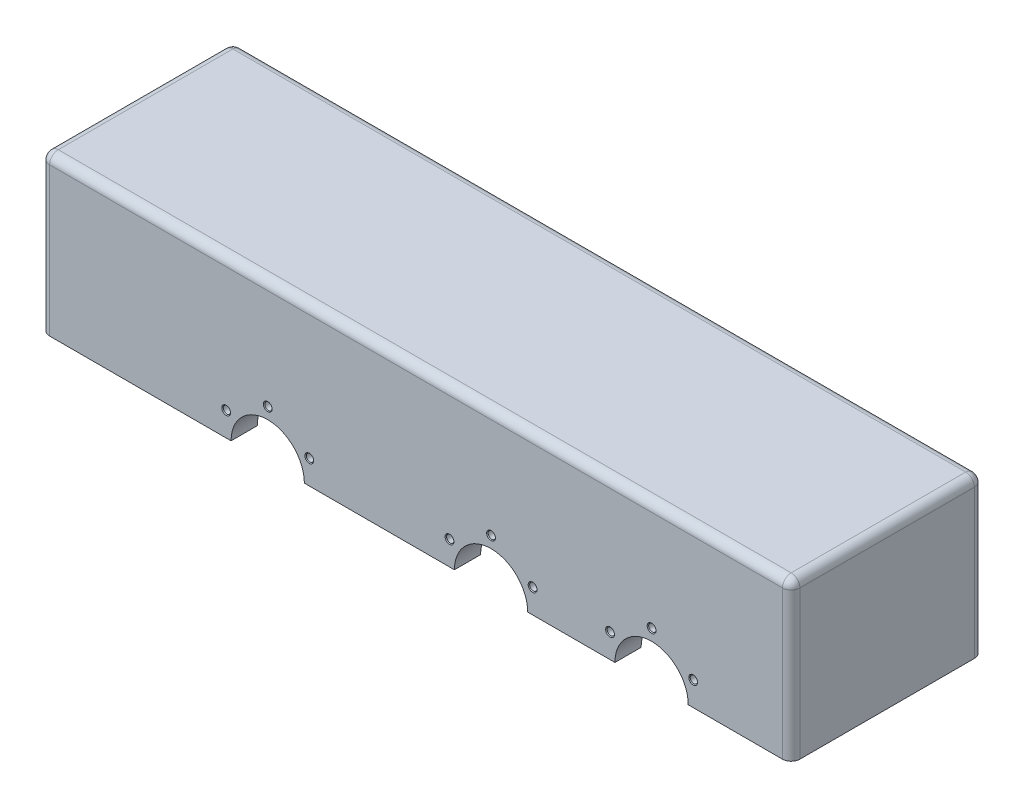
from build123d import *

# Parameters (mm, degrees)
SKETCH1_W           = 430
SKETCH1_H           = 110
SKETCH1_W_2         = 400
SKETCH1_H_2         = 80
BOSS_EXTRUDE1_DEPTH = 80
SKETCH2_W           = 430
SKETCH2_H           = 110
BOSS_EXTRUDE2_DEPTH = 10
SKETCH3_R           = 21
CUT_EXTRUDE1_DEPTH  = 196
FILLET1_R           = 5
CIRPATTERN1_COUNT   = 6
CIRPATTERN2_COUNT   = 6
CIRPATTERN3_COUNT   = 6


with BuildPart() as part:
    # Sketch1 → Boss-Extrude1 (new body)
    with BuildSketch(Plane(origin=(0, 0, 0), x_dir=(1, 0, 0), z_dir=(0, 1, 0))):
        Rectangle(SKETCH1_W, SKETCH1_H)
        Rectangle(SKETCH1_W_2, SKETCH1_H_2, mode=Mode.SUBTRACT)
    extrude(amount=BOSS_EXTRUDE1_DEPTH)

    # Sketch2 → Boss-Extrude2 (add)
    with BuildSketch(Plane(origin=(0, 80, 0), x_dir=(1, 0, 0), z_dir=(0, 1, 0))):
        Rectangle(SKETCH2_W, SKETCH2_H)
    extrude(amount=BOSS_EXTRUDE2_DEPTH)

    # Sketch3 → Cut-Extrude1 (cut)
    with BuildSketch(Plane.XY.offset(55)):
        with Locations((135, 0)):
            Circle(SKETCH3_R)
        with Locations((43, 0)):
            Circle(SKETCH3_R)
        with Locations((-85, 0)):
            Circle(SKETCH3_R)
    extrude(amount=-CUT_EXTRUDE1_DEPTH, mode=Mode.SUBTRACT)

    # Fillet1
    fillet1_edges = [part.edges().sort_by_distance(p)[0] for p in [
        (200, 40, 40),
        (200, 40, -40),
        (-200, 40, -40),
        (-200, 40, 40),
        (200, 80, 0),
        (0, 80, -40),
        (-200, 80, 0),
        (0, 80, 40),
        (215, 90, 0),
        (0, 90, -55),
        (-215, 90, 0),
        (0, 90, 55),
        (215, 45, 55),
        (-215, 45, 55),
        (-215, 45, -55),
        (215, 45, -55),
    ]]
    fillet(fillet1_edges, radius=FILLET1_R)

    # Sketch6 → M5 Tapped Hole1 (revolve, cut)
    with BuildSketch(Plane(origin=(158.815698604, 13.75, -55), x_dir=(0, 1, 0), z_dir=(1, 0, 0))):
        Polygon((0, 0), (0, 13.6618073), (2.1, 12.4), (2.1, 0.425), (2.525, 0), align=None)
    m5_tapped_hole1 = revolve(axis=Axis((158.815698604, 13.75, -61.35), (0, 0, 1)), mode=Mode.SUBTRACT)

    # Sketch7 → M5 Tapped Hole2 (revolve, cut)
    with BuildSketch(Plane(origin=(66.815698604, 13.75, -55), x_dir=(0, 1, 0), z_dir=(1, 0, 0))):
        Polygon((0, 0), (0, 13.6618073), (2.1, 12.4), (2.1, 0.425), (2.525, 0), align=None)
    m5_tapped_hole2 = revolve(axis=Axis((66.815698604, 13.75, -61.35), (0, 0, 1)), mode=Mode.SUBTRACT)

    # Sketch10 → M5 Tapped Hole3 (revolve, cut)
    with BuildSketch(Plane(origin=(-61.184301396, 13.75, -55), x_dir=(0, 1, 0), z_dir=(1, 0, 0))):
        Polygon((0, 0), (0, 13.6618073), (2.1, 12.4), (2.1, 0.425), (2.525, 0), align=None)
    m5_tapped_hole3 = revolve(axis=Axis((-61.184301396, 13.75, -61.35), (0, 0, 1)), mode=Mode.SUBTRACT)

    # CirPattern1: M5 Tapped Hole1 ×6 about axis, 3 skipped
    cirpattern1_axis = Axis((135, 0, 0), (0, 0, 1))
    add([m5_tapped_hole1.rotate(cirpattern1_axis, i * 360 / CIRPATTERN1_COUNT) for i in range(1, CIRPATTERN1_COUNT) if i not in (3, 4, 5)], mode=Mode.SUBTRACT)

    # CirPattern2: M5 Tapped Hole2 ×6 about axis, 3 skipped
    cirpattern2_axis = Axis((43, 0, -141), (0, 0, -1))
    add([m5_tapped_hole2.rotate(cirpattern2_axis, i * 360 / CIRPATTERN2_COUNT) for i in range(1, CIRPATTERN2_COUNT) if i not in (1, 2, 3)], mode=Mode.SUBTRACT)

    # CirPattern3: M5 Tapped Hole3 ×6 about axis, 3 skipped
    cirpattern3_axis = Axis((-85, 0, 0), (0, 0, 1))
    add([m5_tapped_hole3.rotate(cirpattern3_axis, i * 360 / CIRPATTERN3_COUNT) for i in range(1, CIRPATTERN3_COUNT) if i not in (3, 4, 5)], mode=Mode.SUBTRACT)

    # Mirror1: M5 Tapped Hole1, M5 Tapped Hole2, M5 Tapped Hole3 across plane
    add(m5_tapped_hole1.mirror(Plane.XY), mode=Mode.SUBTRACT)
    add(m5_tapped_hole2.mirror(Plane.XY), mode=Mode.SUBTRACT)
    add(m5_tapped_hole3.mirror(Plane.XY), mode=Mode.SUBTRACT)

    # Mirror1 copy 1 sketch → Mirror1 copy 1 (revolve, cut)
    with BuildSketch(Plane(origin=(135, 27.5, 55), x_dir=(-0.866025404, 0.5, 0), z_dir=(0.5, 0.866025404, 0))):
        Polygon((0, 0), (0, -13.6618073), (2.1, -12.4), (2.1, -0.425), (2.525, 0), align=None)
    revolve(axis=Axis((135, 27.5, 61.35), (0, 0, 1)), mode=Mode.SUBTRACT)

    # Mirror1 copy 2 sketch → Mirror1 copy 2 (revolve, cut)
    with BuildSketch(Plane(origin=(111.184301396, 13.75, 55), x_dir=(-0.866025404, -0.5, 0), z_dir=(-0.5, 0.866025404, 0))):
        Polygon((0, 0), (0, -13.6618073), (2.1, -12.4), (2.1, -0.425), (2.525, 0), align=None)
    revolve(axis=Axis((111.184301396, 13.75, 61.35), (0, 0, 1)), mode=Mode.SUBTRACT)

    # Mirror1 copy 3 sketch → Mirror1 copy 3 (revolve, cut)
    with BuildSketch(Plane(origin=(19.184301396, 13.75, 55), x_dir=(-0.866025404, -0.5, 0), z_dir=(-0.5, 0.866025404, 0))):
        Polygon((0, 0), (0, -13.6618073), (2.1, -12.4), (2.1, -0.425), (2.525, 0), align=None)
    revolve(axis=Axis((19.184301396, 13.75, 61.35), (0, 0, 1)), mode=Mode.SUBTRACT)

    # Mirror1 copy 4 sketch → Mirror1 copy 4 (revolve, cut)
    with BuildSketch(Plane(origin=(43, 27.5, 55), x_dir=(-0.866025404, 0.5, 0), z_dir=(0.5, 0.866025404, 0))):
        Polygon((0, 0), (0, -13.6618073), (2.1, -12.4), (2.1, -0.425), (2.525, 0), align=None)
    revolve(axis=Axis((43, 27.5, 61.35), (0, 0, 1)), mode=Mode.SUBTRACT)

    # Mirror1 copy 5 sketch → Mirror1 copy 5 (revolve, cut)
    with BuildSketch(Plane(origin=(-85, 27.5, 55), x_dir=(-0.866025404, 0.5, 0), z_dir=(0.5, 0.866025404, 0))):
        Polygon((0, 0), (0, -13.6618073), (2.1, -12.4), (2.1, -0.425), (2.525, 0), align=None)
    revolve(axis=Axis((-85, 27.5, 61.35), (0, 0, 1)), mode=Mode.SUBTRACT)

    # Mirror1 copy 6 sketch → Mirror1 copy 6 (revolve, cut)
    with BuildSketch(Plane(origin=(-108.815698604, 13.75, 55), x_dir=(-0.866025404, -0.5, 0), z_dir=(-0.5, 0.866025404, 0))):
        Polygon((0, 0), (0, -13.6618073), (2.1, -12.4), (2.1, -0.425), (2.525, 0), align=None)
    revolve(axis=Axis((-108.815698604, 13.75, 61.35), (0, 0, 1)), mode=Mode.SUBTRACT)


solid = part.part
